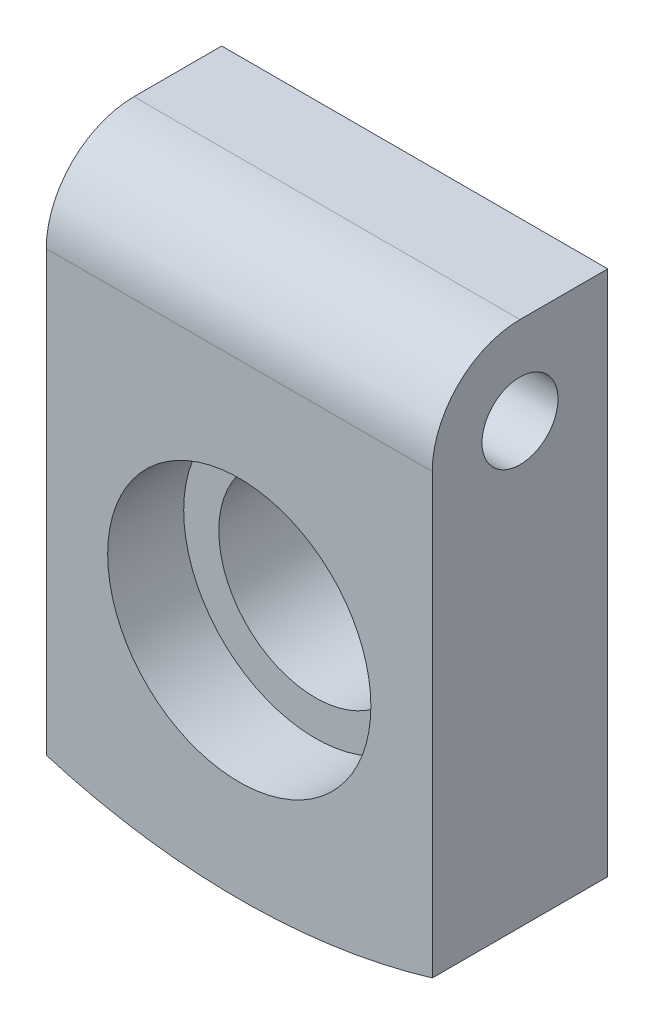
from build123d import *

# Parameters (mm, degrees)
BOSS_EXTRUDE1_DEPTH = 30
SKETCH2_R           = 16.5
CUT_EXTRUDE1_DEPTH  = 17
CUT_EXTRUDE2_REACH  = 15
SKETCH3_R           = 22.5
FILLET2_R           = 15
CUT_EXTRUDE3_REACH  = 68
SKETCH4_R           = 6.5


with BuildPart() as part:
    # Sketch1 → Boss-Extrude1 (new body)
    with BuildSketch(Plane.XY):
        with BuildLine():
            Line((0, 0), (0, 90))
            Line((0, 90), (66, 90))
            Line((66, 90), (66, 0))
            ThreePointArc((66, 0), (33, -4.836485169), (0, 0))
        make_face()
    extrude(amount=BOSS_EXTRUDE1_DEPTH)

    # Sketch2 → Cut-Extrude1 (cut)
    with BuildSketch(Plane(origin=(0, 0, 0), x_dir=(-1, 0, 0), z_dir=(0, 0, -1))):
        with Locations((-33, 35)):
            Circle(SKETCH2_R)
    extrude(amount=-CUT_EXTRUDE1_DEPTH, mode=Mode.SUBTRACT)

    # Sketch3 → Cut-Extrude2 (cut, up to next)
    with BuildSketch(Plane(origin=(0, 0, 17), x_dir=(-1, 0, 0), z_dir=(0, 0, -1)), mode=Mode.PRIVATE) as cut_extrude2_sk1:
        with Locations((-33, 35)):
            Circle(SKETCH3_R)
    cut_extrude2_tool1 = extrude(cut_extrude2_sk1.sketch, amount=-CUT_EXTRUDE2_REACH, mode=Mode.PRIVATE) & part.part
    add(cut_extrude2_tool1.solids().sort_by_distance((33, 35, 17))[0], mode=Mode.SUBTRACT)

    # Fillet2
    fillet2_edges = [part.edges().sort_by_distance(p)[0] for p in [
        (33, 90, 30),
    ]]
    fillet(fillet2_edges, radius=FILLET2_R)

    # Sketch4 → Cut-Extrude3 (cut, up to next)
    with BuildSketch(Plane.ZY, mode=Mode.PRIVATE) as cut_extrude3_sk1:
        with Locations((15, 75)):
            Circle(SKETCH4_R)
    cut_extrude3_tool1 = extrude(cut_extrude3_sk1.sketch, amount=-CUT_EXTRUDE3_REACH, mode=Mode.PRIVATE) & part.part
    add(cut_extrude3_tool1.solids().sort_by_distance((0, 75, 15))[0], mode=Mode.SUBTRACT)


solid = part.part
